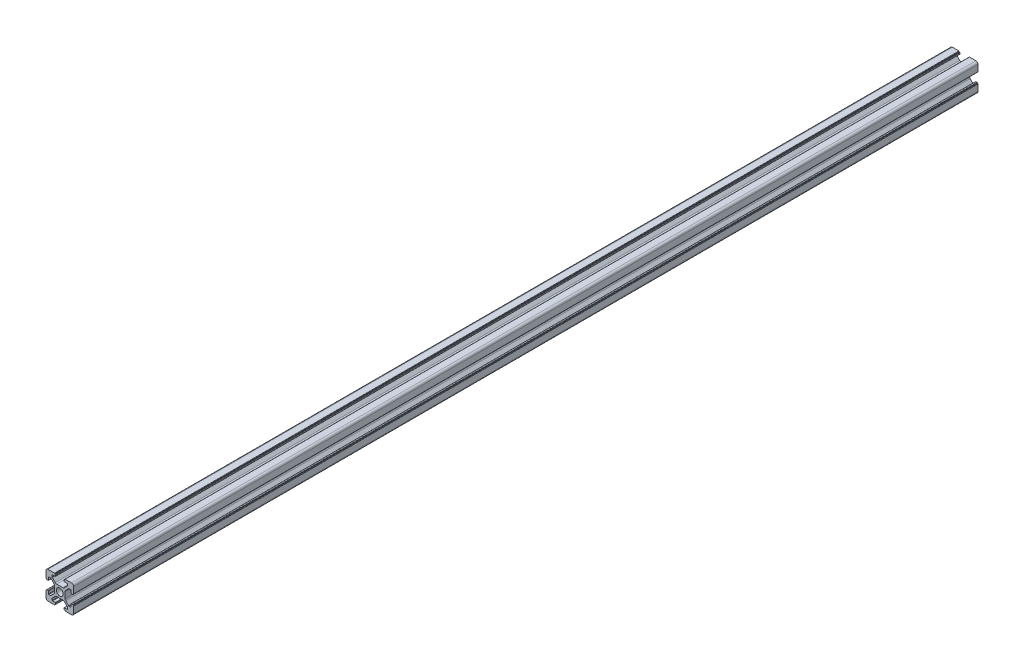
from build123d import *

# Parameters (mm, degrees)
SKETCH_1_R      = 2.5
EXTRUDE_1_DEPTH = 656


with BuildPart() as part:
    # 草图1 → 凸台-拉伸1 (new body)
    with BuildSketch(Plane.XY):
        with BuildLine():
            Line((-8.502261885, -10.002261885), (-3.85, -10.002261885))
            ThreePointArc((-3.85, -10.002261885), (-3.673223305, -9.929038581), (-3.6, -9.752261885))
            Line((-3.6, -9.752261885), (-3.6, -9.502261885))
            Line((-3.6, -9.502261885), (-3.35, -9.502261885))
            ThreePointArc((-3.35, -9.502261885), (-3.173223305, -9.429038581), (-3.1, -9.252261885))
            Line((-3.1, -9.252261885), (-3.1, -8.45))
            ThreePointArc((-3.1, -8.45), (-3.173223305, -8.273223305), (-3.35, -8.2))
            Line((-3.35, -8.2), (-5.25, -8.2))
            ThreePointArc((-5.25, -8.2), (-5.426776695, -8.126776695), (-5.5, -7.95))
            Line((-5.5, -7.95), (-5.5, -6.664213562))
            ThreePointArc((-5.5, -6.664213562), (-5.480969883, -6.568542704), (-5.426776695, -6.487436867))
            Line((-5.426776695, -6.487436867), (-3.278679656, -4.339339828))
            ThreePointArc((-3.278679656, -4.339339828), (-2.792044633, -4.014180701), (-2.218019485, -3.9))
            Line((-2.218019485, -3.9), (2.218019485, -3.9))
            ThreePointArc((2.218019485, -3.9), (2.792044633, -4.014180701), (3.278679656, -4.339339828))
            Line((3.278679656, -4.339339828), (5.426776695, -6.487436867))
            ThreePointArc((5.426776695, -6.487436867), (5.480969883, -6.568542704), (5.5, -6.664213562))
            Line((5.5, -6.664213562), (5.5, -7.95))
            ThreePointArc((5.5, -7.95), (5.426776695, -8.126776695), (5.25, -8.2))
            Line((5.25, -8.2), (3.35, -8.2))
            ThreePointArc((3.35, -8.2), (3.173223305, -8.273223305), (3.1, -8.45))
            Line((3.1, -8.45), (3.1, -9.252261885))
            ThreePointArc((3.1, -9.252261885), (3.173223305, -9.429038581), (3.35, -9.502261885))
            Line((3.35, -9.502261885), (3.6, -9.502261885))
            Line((3.6, -9.502261885), (3.6, -9.752261885))
            ThreePointArc((3.6, -9.752261885), (3.673223305, -9.929038581), (3.85, -10.002261885))
            Line((3.85, -10.002261885), (8.502261885, -10.002261885))
            ThreePointArc((8.502261885, -10.002261885), (9.562922057, -9.562922057), (10.002261885, -8.502261885))
            Line((10.002261885, -8.502261885), (10.002261885, -3.85))
            ThreePointArc((10.002261885, -3.85), (9.929038581, -3.673223305), (9.752261885, -3.6))
            Line((9.752261885, -3.6), (9.502261885, -3.6))
            Line((9.502261885, -3.6), (9.502261885, -3.35))
            ThreePointArc((9.502261885, -3.35), (9.429038581, -3.173223305), (9.252261885, -3.1))
            Line((9.252261885, -3.1), (8.45, -3.1))
            ThreePointArc((8.45, -3.1), (8.273223305, -3.173223305), (8.2, -3.35))
            Line((8.2, -3.35), (8.2, -5.25))
            ThreePointArc((8.2, -5.25), (8.126776695, -5.426776695), (7.95, -5.5))
            Line((7.95, -5.5), (6.664213562, -5.5))
            ThreePointArc((6.664213562, -5.5), (6.568542704, -5.480969883), (6.487436867, -5.426776695))
            Line((6.487436867, -5.426776695), (4.339339828, -3.278679656))
            ThreePointArc((4.339339828, -3.278679656), (4.014180701, -2.792044633), (3.9, -2.218019485))
            Line((3.9, -2.218019485), (3.9, 2.218019485))
            ThreePointArc((3.9, 2.218019485), (4.014180701, 2.792044633), (4.339339828, 3.278679656))
            Line((4.339339828, 3.278679656), (6.487436867, 5.426776695))
            ThreePointArc((6.487436867, 5.426776695), (6.568542704, 5.480969883), (6.664213562, 5.5))
            Line((6.664213562, 5.5), (7.95, 5.5))
            ThreePointArc((7.95, 5.5), (8.126776695, 5.426776695), (8.2, 5.25))
            Line((8.2, 5.25), (8.2, 3.35))
            ThreePointArc((8.2, 3.35), (8.273223305, 3.173223305), (8.45, 3.1))
            Line((8.45, 3.1), (9.252261885, 3.1))
            ThreePointArc((9.252261885, 3.1), (9.429038581, 3.173223305), (9.502261885, 3.35))
            Line((9.502261885, 3.35), (9.502261885, 3.6))
            Line((9.502261885, 3.6), (9.752261885, 3.6))
            ThreePointArc((9.752261885, 3.6), (9.929038581, 3.673223305), (10.002261885, 3.85))
            Line((10.002261885, 3.85), (10.002261885, 8.502261885))
            ThreePointArc((10.002261885, 8.502261885), (9.562922057, 9.562922057), (8.502261885, 10.002261885))
            Line((8.502261885, 10.002261885), (3.85, 10.002261885))
            ThreePointArc((3.85, 10.002261885), (3.673223305, 9.929038581), (3.6, 9.752261885))
            Line((3.6, 9.752261885), (3.6, 9.502261885))
            Line((3.6, 9.502261885), (3.35, 9.502261885))
            ThreePointArc((3.35, 9.502261885), (3.173223305, 9.429038581), (3.1, 9.252261885))
            Line((3.1, 9.252261885), (3.1, 8.45))
            ThreePointArc((3.1, 8.45), (3.173223305, 8.273223305), (3.35, 8.2))
            Line((3.35, 8.2), (5.25, 8.2))
            ThreePointArc((5.25, 8.2), (5.426776695, 8.126776695), (5.5, 7.95))
            Line((5.5, 7.95), (5.5, 6.664213562))
            ThreePointArc((5.5, 6.664213562), (5.480969883, 6.568542704), (5.426776695, 6.487436867))
            Line((5.426776695, 6.487436867), (3.278679656, 4.339339828))
            ThreePointArc((3.278679656, 4.339339828), (2.792044633, 4.014180701), (2.218019485, 3.9))
            Line((2.218019485, 3.9), (-2.218019485, 3.9))
            ThreePointArc((-2.218019485, 3.9), (-2.792044633, 4.014180701), (-3.278679656, 4.339339828))
            Line((-3.278679656, 4.339339828), (-5.426776695, 6.487436867))
            ThreePointArc((-5.426776695, 6.487436867), (-5.480969883, 6.568542704), (-5.5, 6.664213562))
            Line((-5.5, 6.664213562), (-5.5, 7.95))
            ThreePointArc((-5.5, 7.95), (-5.426776695, 8.126776695), (-5.25, 8.2))
            Line((-5.25, 8.2), (-3.35, 8.2))
            ThreePointArc((-3.35, 8.2), (-3.173223305, 8.273223305), (-3.1, 8.45))
            Line((-3.1, 8.45), (-3.1, 9.252261885))
            ThreePointArc((-3.1, 9.252261885), (-3.173223305, 9.429038581), (-3.35, 9.502261885))
            Line((-3.35, 9.502261885), (-3.6, 9.502261885))
            Line((-3.6, 9.502261885), (-3.6, 9.752261885))
            ThreePointArc((-3.6, 9.752261885), (-3.673223305, 9.929038581), (-3.85, 10.002261885))
            Line((-3.85, 10.002261885), (-8.502261885, 10.002261885))
            ThreePointArc((-8.502261885, 10.002261885), (-9.562922057, 9.562922057), (-10.002261885, 8.502261885))
            Line((-10.002261885, 8.502261885), (-10.002261885, 3.85))
            ThreePointArc((-10.002261885, 3.85), (-9.929038581, 3.673223305), (-9.752261885, 3.6))
            Line((-9.752261885, 3.6), (-9.502261885, 3.6))
            Line((-9.502261885, 3.6), (-9.502261885, 3.35))
            ThreePointArc((-9.502261885, 3.35), (-9.429038581, 3.173223305), (-9.252261885, 3.1))
            Line((-9.252261885, 3.1), (-8.45, 3.1))
            ThreePointArc((-8.45, 3.1), (-8.273223305, 3.173223305), (-8.2, 3.35))
            Line((-8.2, 3.35), (-8.2, 5.25))
            ThreePointArc((-8.2, 5.25), (-8.126776695, 5.426776695), (-7.95, 5.5))
            Line((-7.95, 5.5), (-6.664213562, 5.5))
            ThreePointArc((-6.664213562, 5.5), (-6.568542704, 5.480969883), (-6.487436867, 5.426776695))
            Line((-6.487436867, 5.426776695), (-4.339339828, 3.278679656))
            ThreePointArc((-4.339339828, 3.278679656), (-4.014180701, 2.792044633), (-3.9, 2.218019485))
            Line((-3.9, 2.218019485), (-3.9, -2.218019485))
            ThreePointArc((-3.9, -2.218019485), (-4.014180701, -2.792044633), (-4.339339828, -3.278679656))
            Line((-4.339339828, -3.278679656), (-6.487436867, -5.426776695))
            ThreePointArc((-6.487436867, -5.426776695), (-6.568542704, -5.480969883), (-6.664213562, -5.5))
            Line((-6.664213562, -5.5), (-7.95, -5.5))
            ThreePointArc((-7.95, -5.5), (-8.126776695, -5.426776695), (-8.2, -5.25))
            Line((-8.2, -5.25), (-8.2, -3.35))
            ThreePointArc((-8.2, -3.35), (-8.273223305, -3.173223305), (-8.45, -3.1))
            Line((-8.45, -3.1), (-9.252261885, -3.1))
            ThreePointArc((-9.252261885, -3.1), (-9.429038581, -3.173223305), (-9.502261885, -3.35))
            Line((-9.502261885, -3.35), (-9.502261885, -3.6))
            Line((-9.502261885, -3.6), (-9.752261885, -3.6))
            ThreePointArc((-9.752261885, -3.6), (-9.929038581, -3.673223305), (-10.002261885, -3.85))
            Line((-10.002261885, -3.85), (-10.002261885, -8.502261885))
            ThreePointArc((-10.002261885, -8.502261885), (-9.562922057, -9.562922057), (-8.502261885, -10.002261885))
        make_face()
        Circle(SKETCH_1_R, mode=Mode.SUBTRACT)
    extrude(amount=EXTRUDE_1_DEPTH)


solid = part.part
